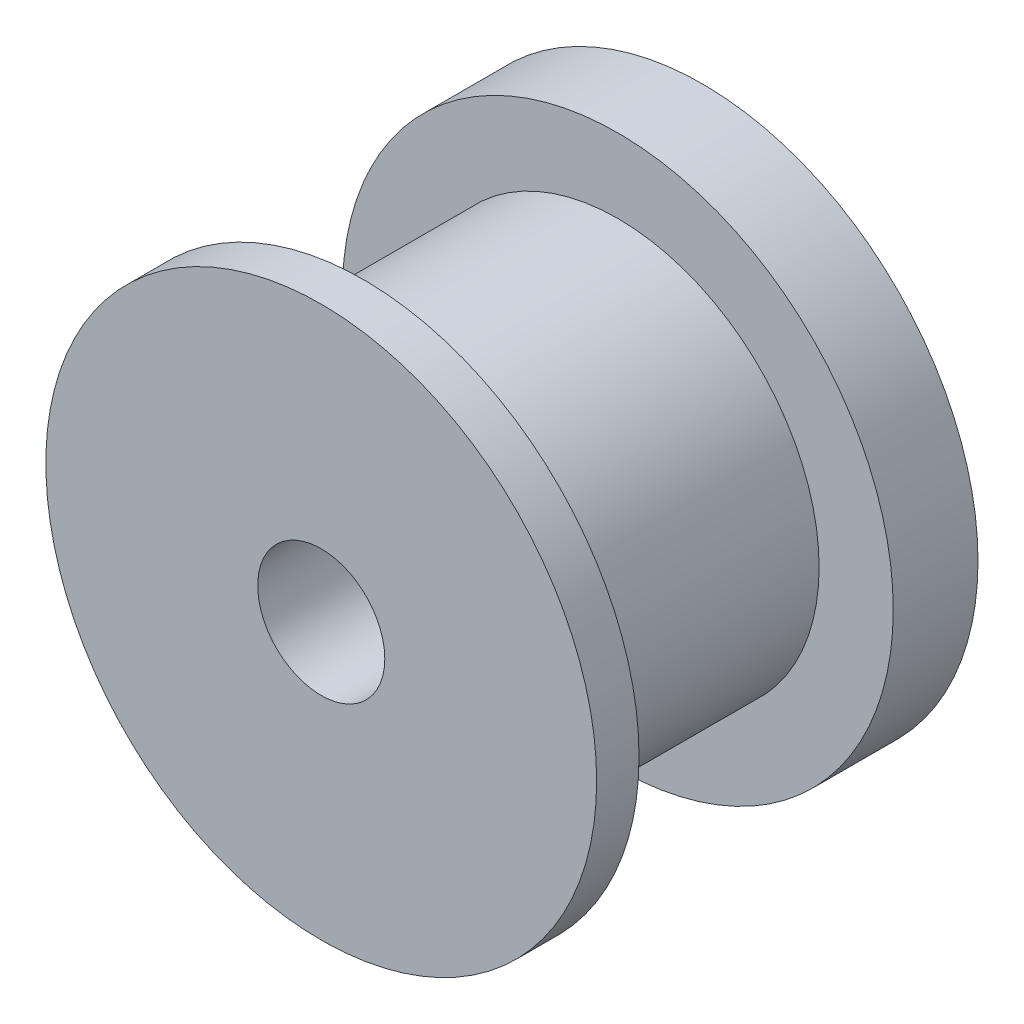
from build123d import *

# Parameters (mm, degrees)
SKETCH_1_R          = 6.5
EXTRUDE_1_DEPTH     = 2
SKETCH_2_R          = 4.75
EXTRUDE_2_DEPTH     = 6
SKETCH_3_R          = 6.5
EXTRUDE_3_DEPTH     = 1
SKETCH_4_R          = 1.5
CUT_EXTRUDE_1_DEPTH = 10


with BuildPart() as part:
    # 草图1 → 凸台-拉伸1 (new body)
    with BuildSketch(Plane.XY):
        Circle(SKETCH_1_R)
    extrude(amount=EXTRUDE_1_DEPTH)

    # 草图2 → 凸台-拉伸2 (add)
    with BuildSketch(Plane.XY.offset(2)):
        Circle(SKETCH_2_R)
    extrude(amount=EXTRUDE_2_DEPTH)

    # 草图3 → 凸台-拉伸3 (add)
    with BuildSketch(Plane.XY.offset(8)):
        Circle(SKETCH_3_R)
    extrude(amount=EXTRUDE_3_DEPTH)

    # 草图4 → 切除-拉伸1 (cut, through all)
    with BuildSketch(Plane.XY.offset(9)):
        Circle(SKETCH_4_R)
    extrude(amount=-CUT_EXTRUDE_1_DEPTH, mode=Mode.SUBTRACT)


solid = part.part
